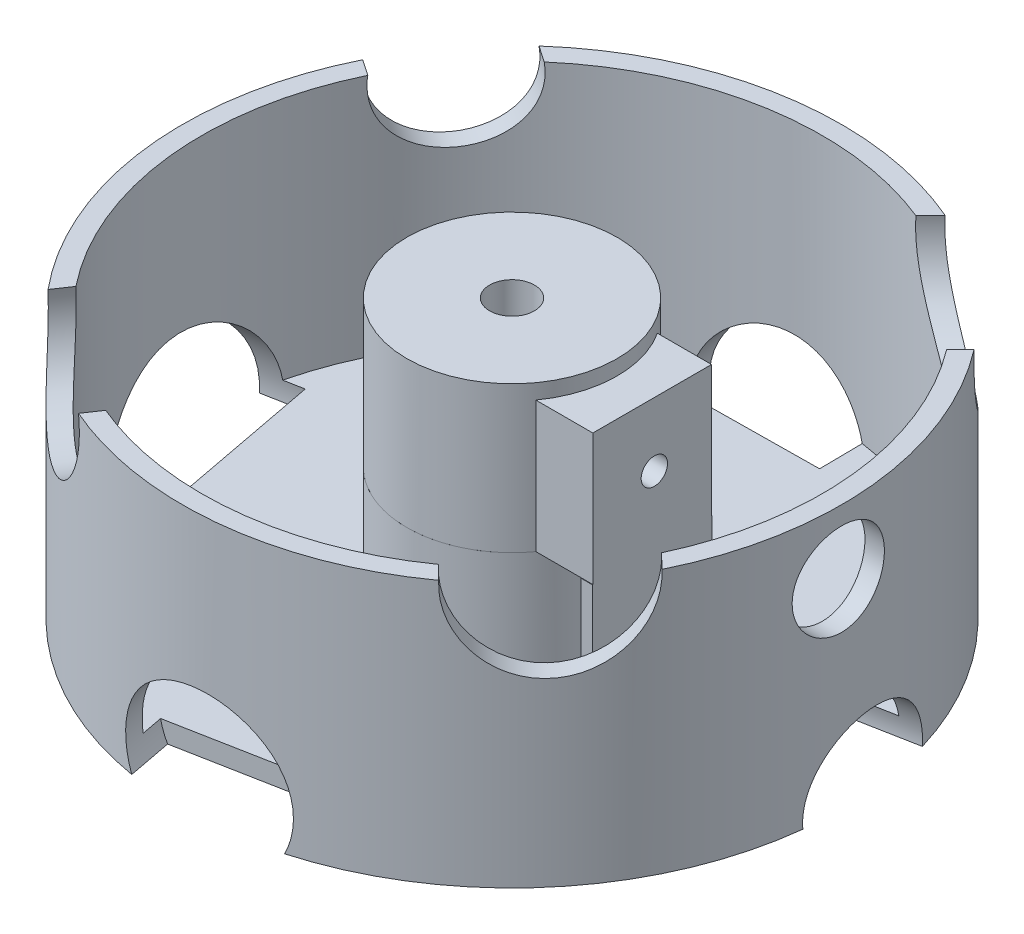
from build123d import *

# Parameters (mm, degrees)
SKETCH1_R                      = 15.958
SHAFTHOLDERNEARMOTOR_DEPTH     = 22.19
SKETCH2_R                      = 3.4
CUT_EXTRUDE1_DEPTH             = 13.55
SKETCH5_W                      = 1.550685087
SKETCH5_H                      = 7.184215806
BOSS_EXTRUDE2_DEPTH            = 13.55
SKETCH7_W                      = 18.003976239
SKETCH7_H                      = 19.909960041
BOSS_EXTRUDE3_DEPTH            = 19
SKETCH6_R                      = 2
CUT_EXTRUDE2_DEPTH             = 1
CUT_EXTRUDE2_DEPTH_BACK        = 19
NUTOPENING_DEPTH               = 30
SKETCH10_R                     = 50
BOSS_EXTRUDE4_DEPTH            = 20
SKETCH12_R                     = 47.082764373
SKETCH12_R_2                   = 15.95790089
CUTTOREMVEEXCESSMATERIAL_DEPTH = 17
SKETCH13_R                     = 50
SKETCH13_R_2                   = 47.082764373
BOSS_EXTRUDE5_DEPTH            = 20
CUT_EXTRUDE6_DEPTH             = 6.933086
SKETCH16_R                     = 7
CUT_EXTRUDE7_DEPTH             = 40
SKETCH19_R                     = 12
CUT_EXTRUDE8_DEPTH             = 10
SKETCH20_R                     = 12
CUT_EXTRUDE9_DEPTH             = 10
SKETCH22_R                     = 12.553525499
CUT_EXTRUDE10_DEPTH            = 10
SKETCH21_R                     = 10
CUT_EXTRUDE11_DEPTH            = 10
SKETCH23_R                     = 11.965333231
CUT_EXTRUDE12_DEPTH            = 10
SKETCH25_R                     = 9.629681042
CUT_EXTRUDE13_DEPTH            = 10
SKETCH26_R                     = 15.012411299
CUT_EXTRUDE14_DEPTH            = 10
SKETCH27_R                     = 11.854712092
CUT_EXTRUDE15_DEPTH            = 10
SKETCH28_W                     = 1.716796753
SKETCH28_H                     = 18.172415452
BOSS_EXTRUDE6_DEPTH            = 17


with BuildPart() as part:
    # Sketch1 → ShaftHolderNearMotor (new body)
    with BuildSketch(Plane(origin=(0, 0, 0), x_dir=(1, 0, 0), z_dir=(0, 1, 0))):
        Circle(SKETCH1_R)
    extrude(amount=SHAFTHOLDERNEARMOTOR_DEPTH)

    # Sketch2 → Cut-Extrude1 (cut)
    with BuildSketch(Plane(origin=(0, 22.19, 0), x_dir=(1, 0, 0), z_dir=(0, 1, 0))):
        Circle(SKETCH2_R)
    extrude(amount=-CUT_EXTRUDE1_DEPTH, mode=Mode.SUBTRACT)

    # Sketch5 → Boss-Extrude2 (add)
    with BuildSketch(Plane(origin=(0, 20.45, 0), x_dir=(1, 0, 0), z_dir=(0, 1, 0))):
        with Locations((3.375342544, 0.020519704)):
            Rectangle(SKETCH5_W, SKETCH5_H)
    extrude(amount=-BOSS_EXTRUDE2_DEPTH)

    # Sketch7 → Boss-Extrude3 (add)
    with BuildSketch(Plane.ZY.offset(-2.6)):
        with Locations((0.33027221, 9.954980021)):
            Rectangle(SKETCH7_W, SKETCH7_H)
    extrude(amount=-BOSS_EXTRUDE3_DEPTH)

    # Sketch6 → Cut-Extrude2 (cut, two sides)
    with BuildSketch(Plane.ZY.offset(-2.6)) as cut_extrude2_sk:
        with Locations((0, 10.236925537)):
            Circle(SKETCH6_R)
    extrude(amount=CUT_EXTRUDE2_DEPTH, mode=Mode.SUBTRACT)
    extrude(cut_extrude2_sk.sketch, amount=-CUT_EXTRUDE2_DEPTH_BACK, mode=Mode.SUBTRACT)

    # Sketch9 → NutOpening (cut)
    with BuildSketch(Plane.XY):
        Polygon((11.876516377, 10.236925537), (11.876516377, 5.861925537), (4.943430227, 5.861925537), (4.943430227, 10.236925537), (4.943430227, 14.614332445), (11.876516377, 14.614332445), align=None)
    extrude(amount=-NUTOPENING_DEPTH, mode=Mode.SUBTRACT)

    # Sketch10 → Boss-Extrude4 (add)
    with BuildSketch(Plane.XZ):
        Circle(SKETCH10_R)
    extrude(amount=BOSS_EXTRUDE4_DEPTH)

    # Sketch12 → CutToRemveExcessMaterial (cut)
    with BuildSketch(Plane(origin=(0, 0, 0), x_dir=(1, 0, 0), z_dir=(0, 1, 0))):
        Circle(SKETCH12_R)
        Circle(SKETCH12_R_2, mode=Mode.SUBTRACT)
    extrude(amount=-CUTTOREMVEEXCESSMATERIAL_DEPTH, mode=Mode.SUBTRACT)

    # Sketch13 → Boss-Extrude5 (add)
    with BuildSketch(Plane(origin=(0, 0, 0), x_dir=(1, 0, 0), z_dir=(0, 1, 0))):
        Circle(SKETCH13_R)
        Circle(SKETCH13_R_2, mode=Mode.SUBTRACT)
    extrude(amount=BOSS_EXTRUDE5_DEPTH)

    # Sketch14 → Cut-Extrude6 (cut)
    with BuildSketch(Plane.ZY.offset(-11.876516377)):
        Polygon((-5.054124256, 10.236925537), (-2.527062128, 5.859925537), (2.527062128, 5.859925537), (5.054124256, 10.236925537), (2.527062128, 14.613925537), (-2.527062128, 14.613925537), align=None)
    extrude(amount=CUT_EXTRUDE6_DEPTH, mode=Mode.SUBTRACT)

    # Sketch16 → Cut-Extrude7 (cut)
    with BuildSketch(Plane(origin=(21.6, 0, 0), x_dir=(0, 0, -1), z_dir=(1, 0, 0))):
        with Locations((0, 10.236925537)):
            Circle(SKETCH16_R)
    extrude(amount=CUT_EXTRUDE7_DEPTH, mode=Mode.SUBTRACT)

    # Sketch19 → Cut-Extrude8 (cut)
    with BuildSketch(Plane(origin=(9.351145186, 0, 49.117777675), x_dir=(0.982355553, 0, -0.187022904), z_dir=(0.187022904, 0, 0.982355553))):
        with Locations((-6.553798813, -15.044376388)):
            Circle(SKETCH19_R)
    extrude(amount=-CUT_EXTRUDE8_DEPTH, mode=Mode.SUBTRACT)

    # Sketch20 → Cut-Extrude9 (cut)
    with BuildSketch(Plane(origin=(35.756785301, 0, 34.949281894), x_dir=(0.698985638, 0, -0.715135706), z_dir=(0.715135706, 0, 0.698985638))):
        with Locations((3.558365894, 19.429208609)):
            Circle(SKETCH20_R)
    extrude(amount=-CUT_EXTRUDE9_DEPTH, mode=Mode.SUBTRACT)

    # Sketch22 → Cut-Extrude10 (cut)
    with BuildSketch(Plane(origin=(34.949281894, 0, -35.756785301), x_dir=(-0.715135706, 0, -0.698985638), z_dir=(0.698985638, 0, -0.715135706))):
        with Locations((5.427738333, 18.490794011)):
            Circle(SKETCH22_R)
    extrude(amount=-CUT_EXTRUDE10_DEPTH, mode=Mode.SUBTRACT)

    # Sketch21 → Cut-Extrude11 (cut)
    with BuildSketch(Plane(origin=(49.117777675, 0, -9.351145186), x_dir=(-0.187022904, 0, -0.982355553), z_dir=(0.982355553, 0, -0.187022904))):
        with Locations((-4.791175632, -19.221882877)):
            Circle(SKETCH21_R)
    extrude(amount=-CUT_EXTRUDE11_DEPTH, mode=Mode.SUBTRACT)

    # Sketch23 → Cut-Extrude12 (cut)
    with BuildSketch(Plane(origin=(-0.570991135, 0, -49.996739585), x_dir=(-0.999934792, 0, 0.011419823), z_dir=(-0.011419823, 0, -0.999934792))):
        with Locations((4.525183767, -20.017770037)):
            Circle(SKETCH23_R)
    extrude(amount=-CUT_EXTRUDE12_DEPTH, mode=Mode.SUBTRACT)

    # Sketch25 → Cut-Extrude13 (cut)
    with BuildSketch(Plane(origin=(-41.343771844, 0, -28.119255498), x_dir=(-0.56238511, 0, 0.826875437), z_dir=(-0.826875437, 0, -0.56238511))):
        with Locations((-2.649823638, 18.643158668)):
            Circle(SKETCH25_R)
    extrude(amount=-CUT_EXTRUDE13_DEPTH, mode=Mode.SUBTRACT)

    # Sketch26 → Cut-Extrude14 (cut)
    with BuildSketch(Plane(origin=(-49.117777675, 0, 9.351145186), x_dir=(0.187022904, 0, 0.982355553), z_dir=(-0.982355553, 0, 0.187022904))):
        with Locations((-4.497650602, -19.126376963)):
            Circle(SKETCH26_R)
    extrude(amount=-CUT_EXTRUDE14_DEPTH, mode=Mode.SUBTRACT)

    # Sketch27 → Cut-Extrude15 (cut)
    with BuildSketch(Plane(origin=(-28.119255498, 0, 41.343771844), x_dir=(0.826875437, 0, 0.56238511), z_dir=(-0.56238511, 0, 0.826875437))):
        with Locations((-2.287517393, 17.62218093)):
            Circle(SKETCH27_R)
    extrude(amount=-CUT_EXTRUDE15_DEPTH, mode=Mode.SUBTRACT)

    # Sketch28 → Boss-Extrude6 (add)
    with BuildSketch(Plane.XZ):
        with Locations((20.741601624, 0.317955018)):
            Rectangle(SKETCH28_W, SKETCH28_H)
    extrude(amount=BOSS_EXTRUDE6_DEPTH)


solid = part.part
